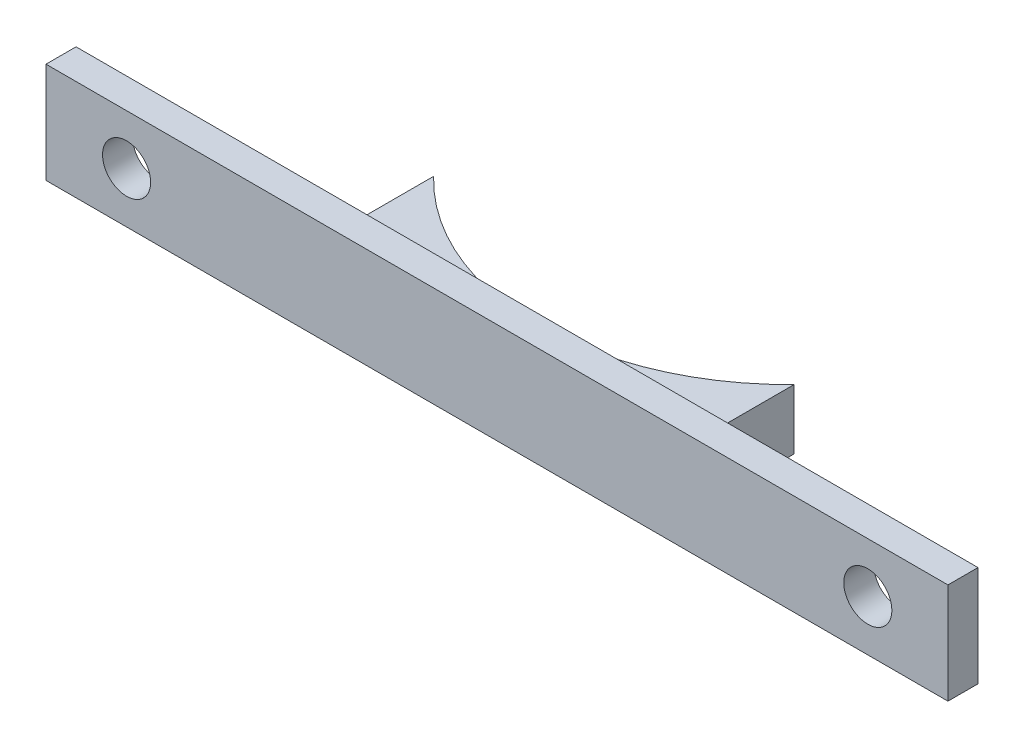
from build123d import *

# Parameters (mm, degrees)
SKETCH2_W                = 114.356575713
SKETCH2_H                = 12.768326156
SKETCH2_R                = 3.048
BOSS_EXTRUDE1_DEPTH      = 3.81
BOSS_EXTRUDE2_DEPTH      = 3.81
BOSS_EXTRUDE2_DEPTH_BACK = 3.81


with BuildPart() as part:
    # Sketch2 → Boss-Extrude1 (new body)
    with BuildSketch(Plane.XY):
        with Locations((-0.028287857, -0.034163078)):
            Rectangle(SKETCH2_W, SKETCH2_H)
        with Locations((-46.99, 0)):
            Circle(SKETCH2_R, mode=Mode.SUBTRACT)
        with Locations((46.99, 0)):
            Circle(SKETCH2_R, mode=Mode.SUBTRACT)
    extrude(amount=BOSS_EXTRUDE1_DEPTH)

    # Sketch3 → Boss-Extrude2 (add, two sides)
    with BuildSketch(Plane(origin=(0, 0, 0), x_dir=(1, 0, 0), z_dir=(0, 1, 0))) as boss_extrude2_sk:
        with BuildLine():
            Line((0, 0), (22.86, 0))
            Line((22.86, 0), (22.86, 10.986323502))
            ThreePointArc((22.86, 10.986323502), (0, 1.27), (-22.86, 10.986323502))
            Line((-22.86, 10.986323502), (-22.86, 0))
            Line((-22.86, 0), (0, 0))
        make_face()
    extrude(amount=BOSS_EXTRUDE2_DEPTH)
    extrude(boss_extrude2_sk.sketch, amount=-BOSS_EXTRUDE2_DEPTH_BACK)


solid = part.part
